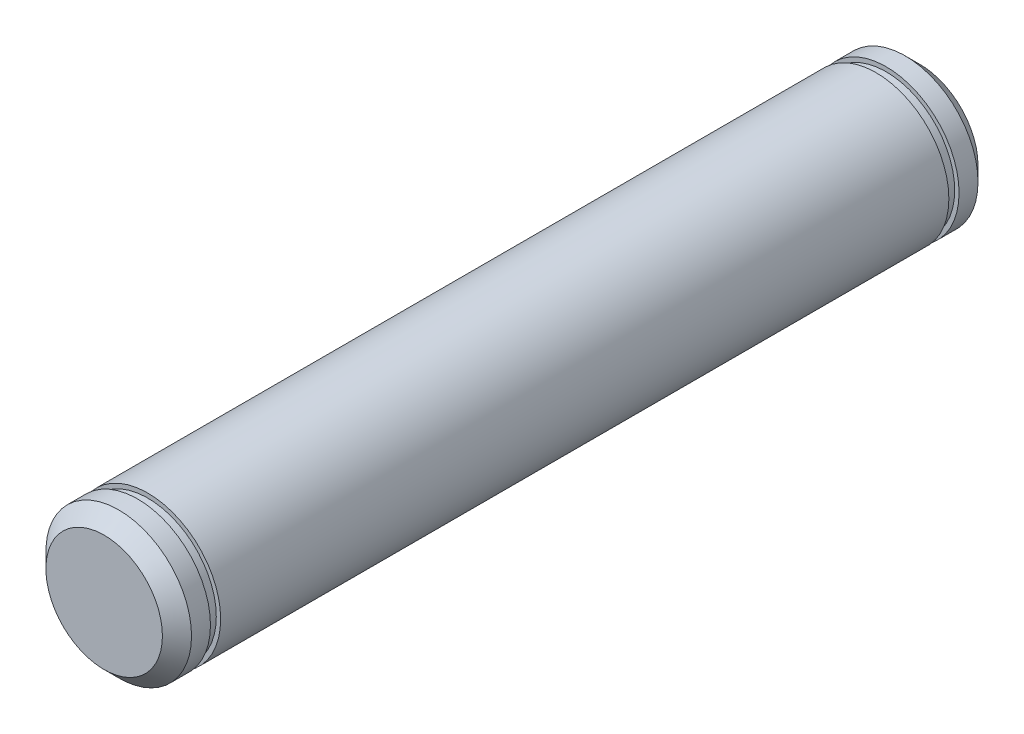
from build123d import *

# Parameters (mm, degrees)
BOSS_EXTRUDE1_DEPTH      = 28
BOSS_EXTRUDE1_DEPTH_BACK = 28
SKETCH1_R                = 5
SKETCH2_R                = 14.7
SKETCH2_R_2              = 4.7
CUT_EXTRUDE_THIN1_DEPTH  = 0.7
CHAMFER1_SIZE            = 1


with BuildPart() as part:
    # Sketch1 → Boss-Extrude1 (new, two sides: drawn at the far end of the back side and taken through both)
    with BuildSketch(Plane.XY.offset(-BOSS_EXTRUDE1_DEPTH_BACK)):
        Circle(SKETCH1_R)
    extrude(amount=BOSS_EXTRUDE1_DEPTH + BOSS_EXTRUDE1_DEPTH_BACK)

    # Sketch2 → Cut-Extrude-Thin1 (cut)
    with BuildSketch(Plane.XY.offset(25)):
        Circle(SKETCH2_R)
        Circle(SKETCH2_R_2, mode=Mode.SUBTRACT)
    cut_extrude_thin1 = extrude(amount=CUT_EXTRUDE_THIN1_DEPTH, mode=Mode.SUBTRACT)

    # Mirror1: Cut-Extrude-Thin1 across plane
    add(cut_extrude_thin1.mirror(Plane.XY), mode=Mode.SUBTRACT)

    # Chamfer1
    chamfer1_edges = [part.edges().sort_by_distance(p)[0] for p in [
        (-5, 0, -28),
        (-5, 0, 28),
    ]]
    chamfer(chamfer1_edges, length=CHAMFER1_SIZE)


solid = part.part
